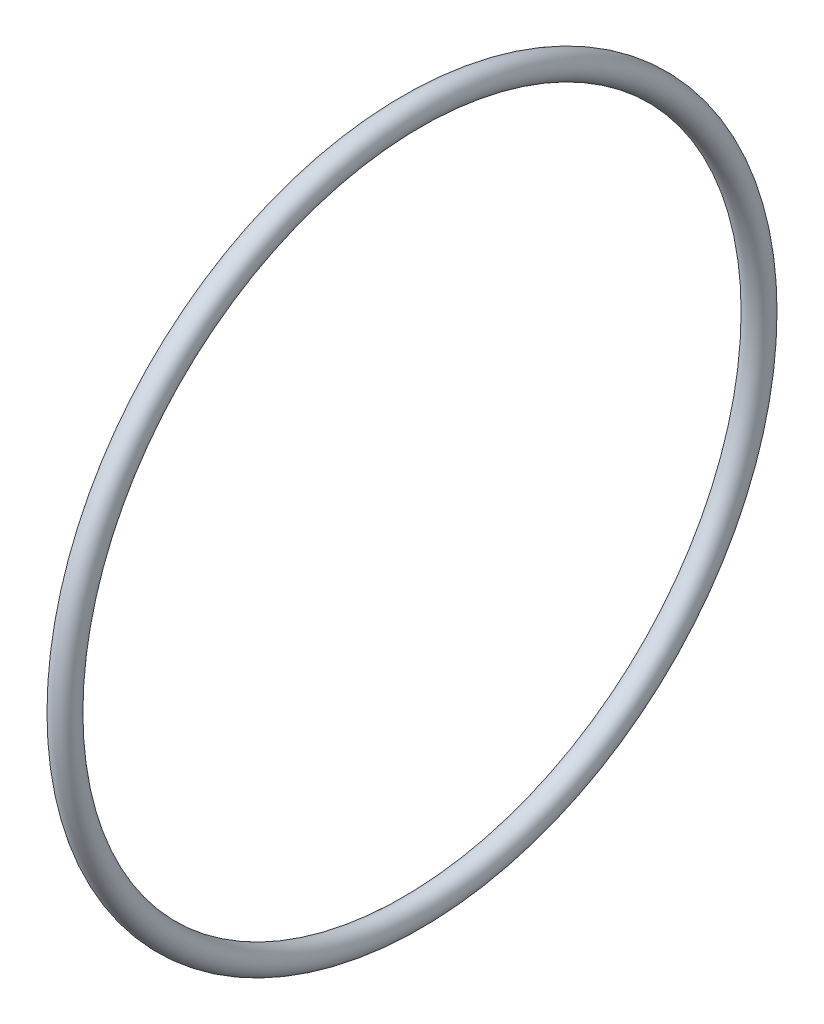
from build123d import *

# Parameters (mm, degrees)
SKETCH3_R = 0.950000005


with BuildPart() as part:
    # Sketch3 → Revolve1 (revolve)
    with BuildSketch(Plane.XY):
        with Locations((26.889800043, 25.950000043)):
            Circle(SKETCH3_R)
    revolve(axis=Axis((0, 0, 0), (1, 0, 0)))


solid = part.part
